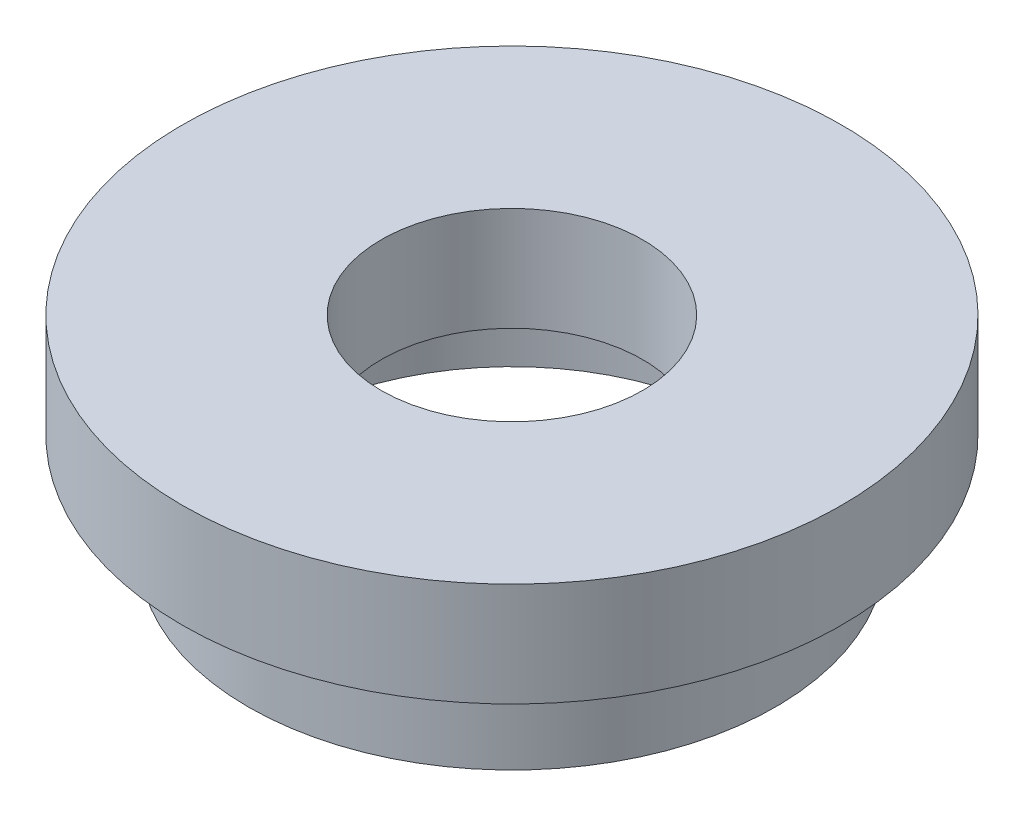
from build123d import *


with BuildPart() as part:
    # 草图1 → 旋转1 (revolve)
    with BuildSketch(Plane.XY, mode=Mode.PRIVATE) as revolve_1_sk:
        Polygon((12.7, 0), (11.1, 0), (11.1, 4), (11.7, 4), (11.7, 5), (6.295, 5), (6.295, 10), (15.875, 10), (15.875, 5), (12.55, 5), (12.55, 4), (12.7, 4), align=None)
    revolve(revolve_1_sk.sketch.rotate(Axis((0, 13.744680851, 0), (0, -1, 0)), 90), axis=Axis((0, 13.744680851, 0), (0, -1, 0)))  # turned: the seam where the file's is


solid = part.part
